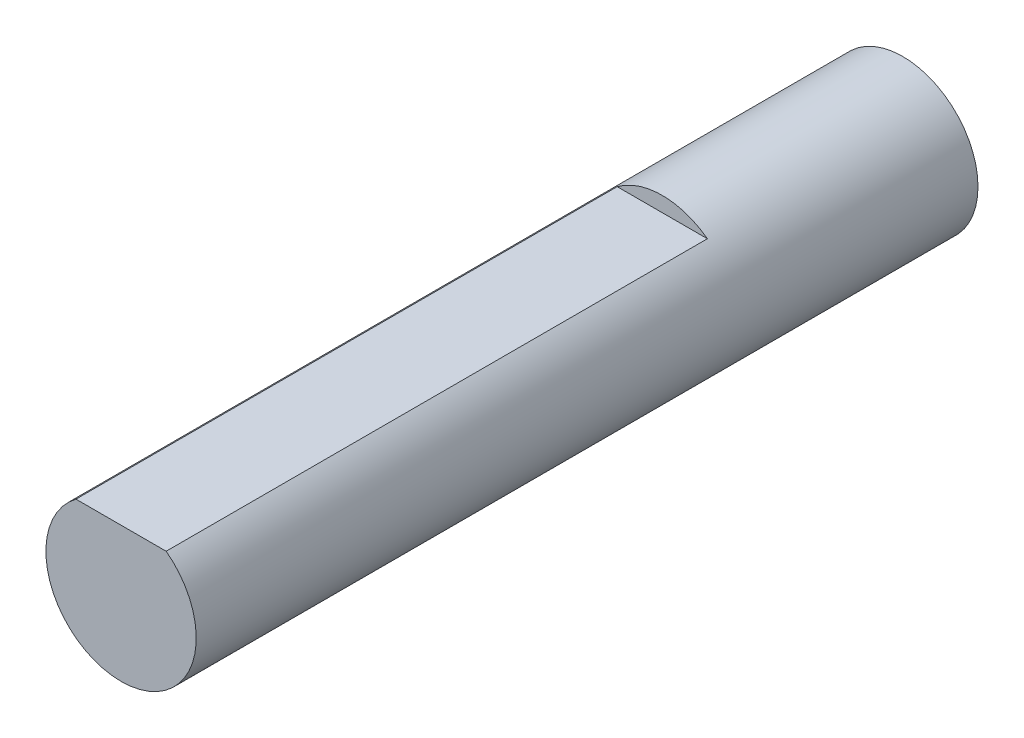
from build123d import *

# Parameters (mm, degrees)
SKETCH1_R           = 2.5
BOSS_EXTRUDE1_DEPTH = 26
SKETCH2_W           = 3.423588914
SKETCH2_H           = 0.513616332
CUT_EXTRUDE2_DEPTH  = 18


with BuildPart() as part:
    # Sketch1 → Boss-Extrude1 (new body)
    with BuildSketch(Plane.XY):
        with Locations((-10.740516012, 9.685643904)):
            Circle(SKETCH1_R)
    extrude(amount=BOSS_EXTRUDE1_DEPTH)

    # Sketch2 → Cut-Extrude2 (cut)
    with BuildSketch(Plane.XY.offset(26)):
        with Locations((-10.722110774, 11.94245207)):
            Rectangle(SKETCH2_W, SKETCH2_H)
    extrude(amount=-CUT_EXTRUDE2_DEPTH, mode=Mode.SUBTRACT)


solid = part.part
